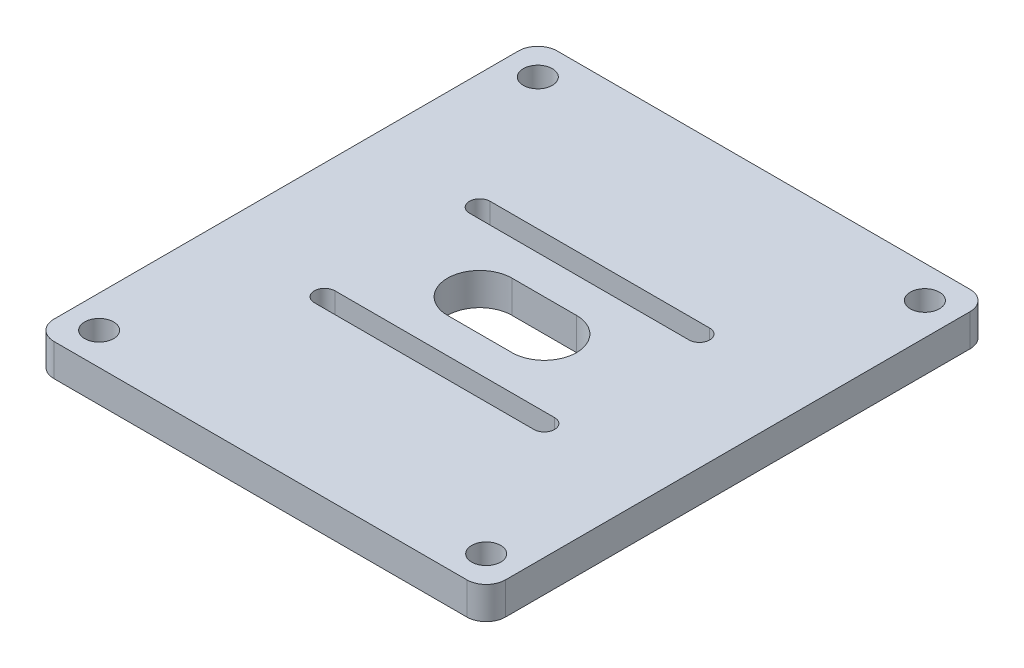
from build123d import *

# Parameters (mm, degrees)
SKETCH1_W           = 70
SKETCH1_H           = 78
SKETCH1_R           = 2.25
BOSS_EXTRUDE1_DEPTH = 5
FILLET1_R           = 3


with BuildPart() as part:
    # Sketch1 → Boss-Extrude1 (new body)
    with BuildSketch(Plane(origin=(0, 0, 0), x_dir=(1, 0, 0), z_dir=(0, 1, 0))):
        with Locations((-5, 0)):
            Rectangle(SKETCH1_W, SKETCH1_H)
        with Locations((-35, 34)):
            Circle(SKETCH1_R, mode=Mode.SUBTRACT)
        with Locations((25, 34)):
            Circle(SKETCH1_R, mode=Mode.SUBTRACT)
        with Locations((25, -34)):
            Circle(SKETCH1_R, mode=Mode.SUBTRACT)
        with Locations((-35, -34)):
            Circle(SKETCH1_R, mode=Mode.SUBTRACT)
        with BuildLine():
            Line((-22.02081528, 13.62081528), (12.02081528, 13.62081528))
            ThreePointArc((12.02081528, 13.62081528), (13.62081528, 12.02081528), (12.02081528, 10.42081528))
            Line((12.02081528, 10.42081528), (-22.02081528, 10.42081528))
            ThreePointArc((-22.02081528, 10.42081528), (-23.62081528, 12.02081528), (-22.02081528, 13.62081528))
        make_face(mode=Mode.SUBTRACT)
        with BuildLine():
            Line((-22.02081528, -13.62081528), (12.02081528, -13.62081528))
            ThreePointArc((12.02081528, -13.62081528), (13.62081528, -12.02081528), (12.02081528, -10.42081528))
            Line((12.02081528, -10.42081528), (-22.02081528, -10.42081528))
            ThreePointArc((-22.02081528, -10.42081528), (-23.62081528, -12.02081528), (-22.02081528, -13.62081528))
        make_face(mode=Mode.SUBTRACT)
        with BuildLine():
            Line((-10, 5), (0, 5))
            ThreePointArc((0, 5), (5, 0), (0, -5))
            Line((0, -5), (-10, -5))
            ThreePointArc((-10, -5), (-15, 0), (-10, 5))
        make_face(mode=Mode.SUBTRACT)
    extrude(amount=BOSS_EXTRUDE1_DEPTH)

    # Fillet1
    fillet1_edges = [part.edges().sort_by_distance(p)[0] for p in [
        (30, 2.5, -39),
        (30, 2.5, 39),
        (-40, 2.5, 39),
        (-40, 2.5, -39),
    ]]
    fillet(fillet1_edges, radius=FILLET1_R)


solid = part.part
